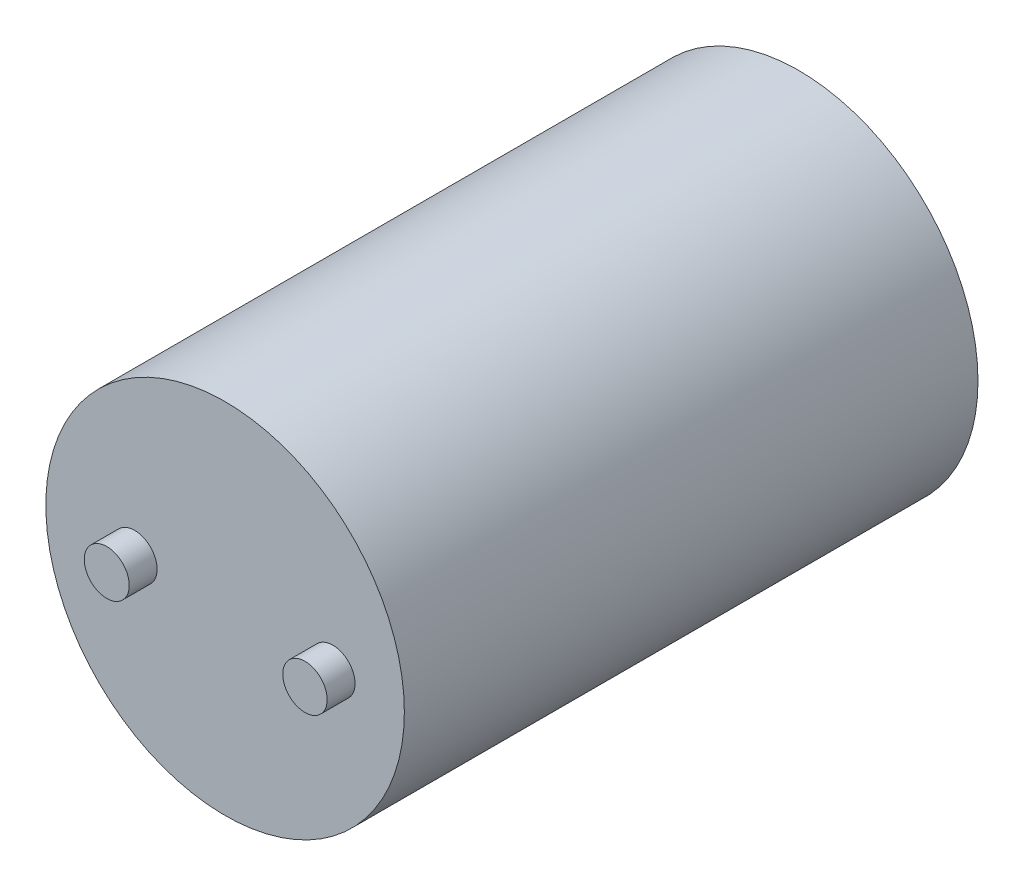
from build123d import *

# Parameters (mm, degrees)
SKETCH1_R           = 45
BOSS_EXTRUDE1_DEPTH = 144
SKETCH2_R           = 5.645084992
SKETCH2_R_2         = 5.573002613
BOSS_EXTRUDE2_DEPTH = 7


with BuildPart() as part:
    # Sketch1 → Boss-Extrude1 (new body)
    with BuildSketch(Plane.XY):
        Circle(SKETCH1_R)
    extrude(amount=BOSS_EXTRUDE1_DEPTH)

    # Sketch2 → Boss-Extrude2 (add)
    with BuildSketch(Plane.XY.offset(144)):
        with Locations((-22.710039741, 0)):
            Circle(SKETCH2_R)
        with Locations((27.048206136, 0)):
            Circle(SKETCH2_R_2)
    extrude(amount=BOSS_EXTRUDE2_DEPTH)


solid = part.part
